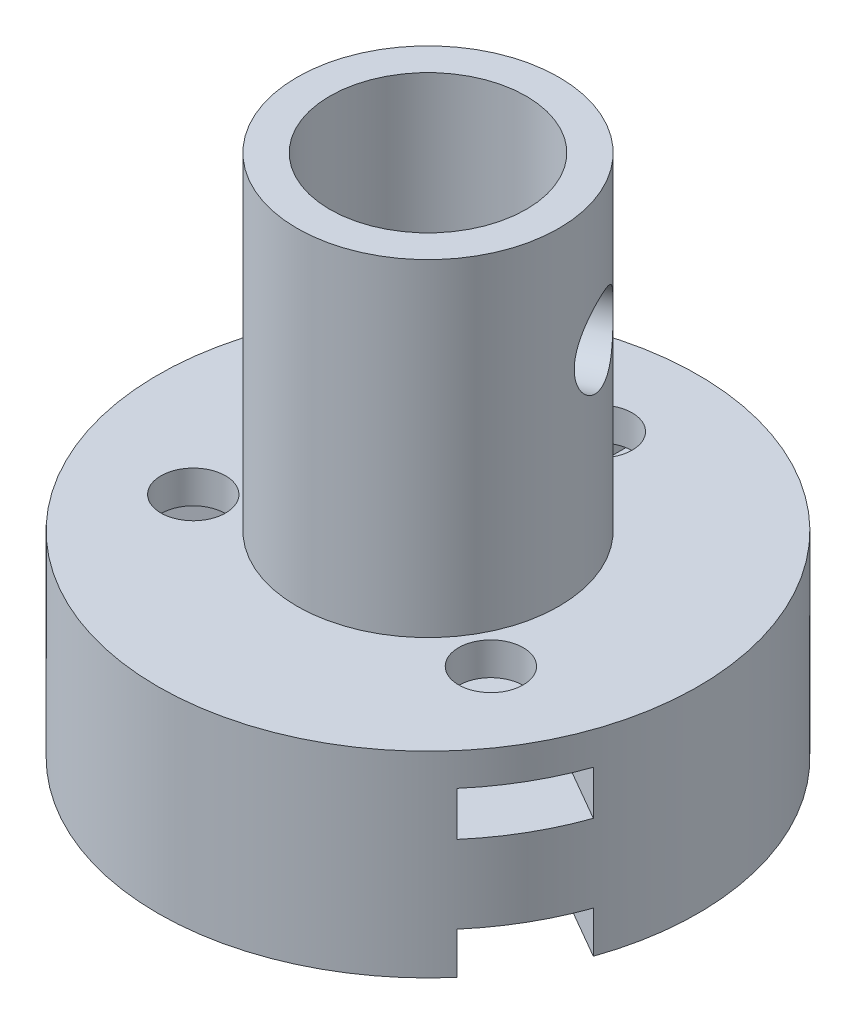
from build123d import *

# Parameters (mm, degrees)
CROQUIS1_R              = 16.5
SALIENTE_EXTRUIR1_DEPTH = 12
CROQUIS2_R              = 1.975
CROQUIS2_W              = 6.1
CROQUIS2_H              = 12
CORTAR_EXTRUIR1_DEPTH   = 2.55
CROQUIS2_2_R            = 1.975
CORTAR_EXTRUIR2_DEPTH   = 27.239283527
CORTAR_EXTRUIR3_START   = -2.7
CROQUIS3_W              = 6.1
CROQUIS3_H              = 12
CROQUIS3_R              = 1.975
CORTAR_EXTRUIR3_DEPTH   = 2.7
CROQUIS4_R              = 8
CROQUIS4_R_2            = 6
EXTRUIR_L_MINA1_DEPTH   = 20
CORTAR_EXTRUIR4_REACH   = 46.535
CROQUIS5_R              = 2.45


with BuildPart() as part:
    # Croquis1 → Saliente-Extruir1 (new body)
    with BuildSketch(Plane(origin=(0, 0, 0), x_dir=(1, 0, 0), z_dir=(0, 1, 0))):
        Circle(CROQUIS1_R)
    extrude(amount=SALIENTE_EXTRUIR1_DEPTH)

    # Croquis2 → Cortar-Extruir1 (cut)
    # profile 1 of 3: a face of its own
    with BuildSketch(Plane.XZ):
        Polygon((-12.764419162, 10.891377482), (-15.814419162, 5.608622518), (-5.422114317, -0.391377482), (-2.372114317, 4.891377482), align=None)
        with Locations((-9.09326674, 5.25)):
            Circle(CROQUIS2_R, mode=Mode.SUBTRACT)
    # profile 2 of 3: a face of its own
    with BuildSketch(Plane.XZ):
        with Locations((0, -10.5)):
            Rectangle(CROQUIS2_W, CROQUIS2_H)
        with Locations((0, -10.5)):
            Circle(CROQUIS2_R, mode=Mode.SUBTRACT)
    # profile 3 of 3: a face of its own
    with BuildSketch(Plane.XZ):
        Polygon((15.814419162, 5.608622518), (12.764419162, 10.891377482), (2.372114317, 4.891377482), (5.422114317, -0.391377482), align=None)
        with Locations((9.09326674, 5.25)):
            Circle(CROQUIS2_R, mode=Mode.SUBTRACT)
    extrude(amount=-CORTAR_EXTRUIR1_DEPTH, mode=Mode.SUBTRACT)

    # Croquis2_2 → Cortar-Extruir2 (cut, through all)
    with BuildSketch(Plane.XZ):
        with Locations((0, -10.5)):
            Circle(CROQUIS2_2_R)
        with Locations((-9.09326674, 5.25)):
            Circle(CROQUIS2_2_R)
        with Locations((9.09326674, 5.25)):
            Circle(CROQUIS2_2_R)
    extrude(amount=-CORTAR_EXTRUIR2_DEPTH, mode=Mode.SUBTRACT)

    # Croquis3 → Cortar-Extruir3 (cut)
    # profile 1 of 3: a face of its own
    with BuildSketch(Plane(origin=(0, 10, 0), x_dir=(1, 0, 0), z_dir=(0, 1, 0)).offset(CORTAR_EXTRUIR3_START)):
        with Locations((0, 10.5)):
            Rectangle(CROQUIS3_W, CROQUIS3_H)
        with Locations((0, 10.5)):
            Circle(CROQUIS3_R, mode=Mode.SUBTRACT)
    # profile 2 of 3: a face of its own
    with BuildSketch(Plane(origin=(0, 10, 0), x_dir=(1, 0, 0), z_dir=(0, 1, 0)).offset(CORTAR_EXTRUIR3_START)):
        Polygon((12.764419162, -10.891377482), (15.814419162, -5.608622518), (5.422114317, 0.391377482), (2.372114317, -4.891377482), align=None)
        with Locations((9.09326674, -5.25)):
            Circle(CROQUIS3_R, mode=Mode.SUBTRACT)
    # profile 3 of 3: a face of its own
    with BuildSketch(Plane(origin=(0, 10, 0), x_dir=(1, 0, 0), z_dir=(0, 1, 0)).offset(CORTAR_EXTRUIR3_START)):
        Polygon((-15.814419162, -5.608622518), (-12.764419162, -10.891377482), (-2.372114317, -4.891377482), (-5.422114317, 0.391377482), align=None)
        with Locations((-9.09326674, -5.25)):
            Circle(CROQUIS3_R, mode=Mode.SUBTRACT)
    extrude(amount=CORTAR_EXTRUIR3_DEPTH, mode=Mode.SUBTRACT)

    # Croquis4 → Extruir-Lámina1 (add)
    with BuildSketch(Plane(origin=(0, 12, 0), x_dir=(1, 0, 0), z_dir=(0, 1, 0))):
        Circle(CROQUIS4_R)
        Circle(CROQUIS4_R_2, mode=Mode.SUBTRACT)
    extrude(amount=EXTRUIR_L_MINA1_DEPTH)

    # Croquis5 → Cortar-Extruir4 (cut, up to next)
    with BuildSketch(Plane(origin=(7.250462296, 0, -3.380946094), x_dir=(0, -1, 0), z_dir=(0.906307787036651, 0, -0.4226182617406972)), mode=Mode.PRIVATE) as cortar_extruir4_sk1:
        with Locations((-24, 0)):
            Circle(CROQUIS5_R)
    cortar_extruir4_tool1 = extrude(cortar_extruir4_sk1.sketch, amount=-CORTAR_EXTRUIR4_REACH, mode=Mode.PRIVATE) & part.part
    add(cortar_extruir4_tool1.solids().sort_by_distance((7.250462, 24, -3.380946))[0], mode=Mode.SUBTRACT)


solid = part.part
